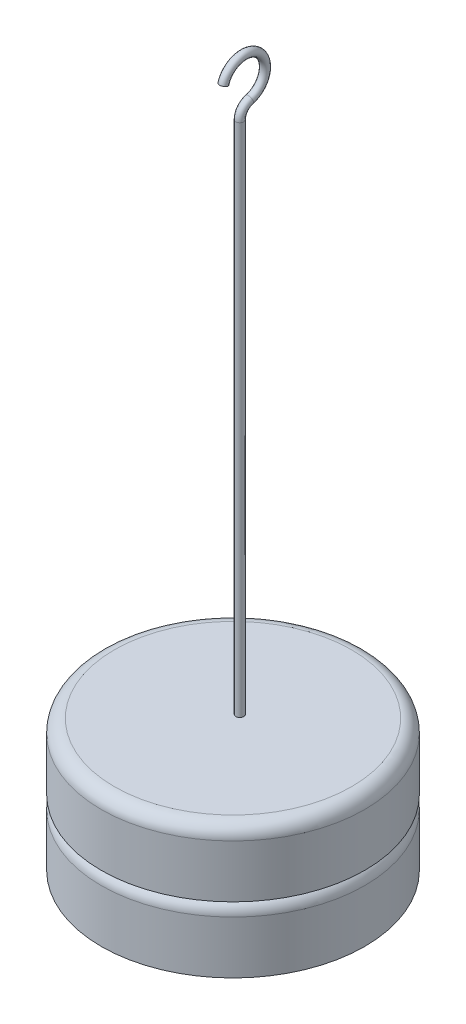
from build123d import *

# Parameters (mm, degrees)
SKETCH1_R           = 12.7
BOSS_EXTRUDE1_DEPTH = 6.35
FILLET1_R           = 1.27
SKETCH2_R           = 12.7
BOSS_EXTRUDE2_DEPTH = 6.35
FILLET2_R           = 1.27
SWEEP1_PROFILE_R    = 0.381


with BuildPart() as part:
    # Sketch1 → Boss-Extrude1 (new body)
    with BuildSketch(Plane(origin=(0, 0, 0), x_dir=(1, 0, 0), z_dir=(0, 1, 0))):
        Circle(SKETCH1_R)
    extrude(amount=BOSS_EXTRUDE1_DEPTH)

    # Fillet1
    fillet1_edges = [part.edges().sort_by_distance(p)[0] for p in [
        (-12.7, 6.35, 0),
    ]]
    fillet(fillet1_edges, radius=FILLET1_R)

    # Sketch2 → Boss-Extrude2 (add)
    with BuildSketch(Plane(origin=(0, 6.35, 0), x_dir=(1, 0, 0), z_dir=(0, 1, 0))):
        Circle(SKETCH2_R)
    extrude(amount=BOSS_EXTRUDE2_DEPTH)

    # Fillet2
    fillet2_edges = [part.edges().sort_by_distance(p)[0] for p in [
        (-12.7, 12.7, 0),
    ]]
    fillet(fillet2_edges, radius=FILLET2_R)

    # Sweep1: sweep along a path in Sketch4
    with BuildLine(Plane(origin=(0, 0, 0), x_dir=(0, 0, -1), z_dir=(1, 0, 0))) as sweep1_path:
        Line((0.653856162, 12.7), (0.653856162, 62.335507358))
        ThreePointArc((0.653856162, 62.335507358), (0.91265079, 63.103858642), (1.58356277, 63.559067903))
        ThreePointArc((1.58356277, 63.559067903), (2.483877112, 66.979023941), (-0.937317322, 66.083427011))
    # Sweep1 profile (on start of the path) → Sweep1 (sweep)
    with BuildSketch(Plane(origin=(0, 12.7, -0.653856162), x_dir=(0, 0, 1), z_dir=(0, 1, 0))):
        Circle(SWEEP1_PROFILE_R)
    sweep(path=sweep1_path.line)


solid = part.part
